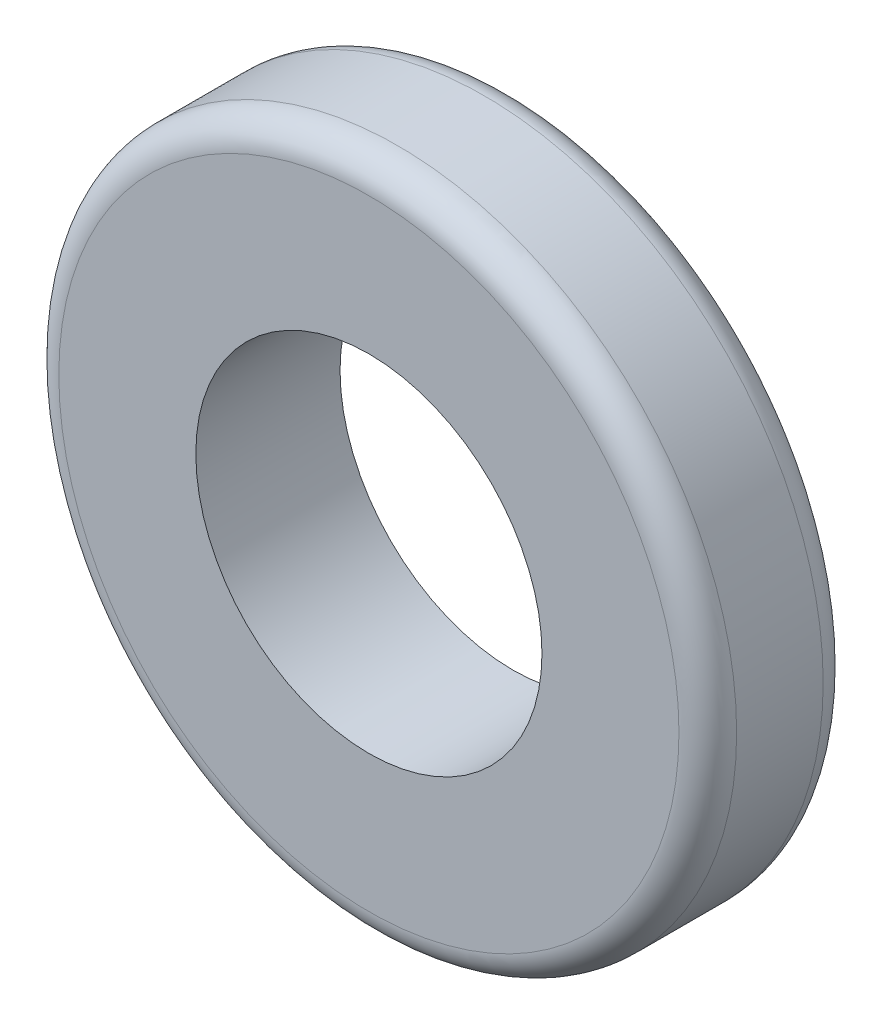
from build123d import *

# Parameters (mm, degrees)
SKETCH1_R           = 23.5
SKETCH1_R_2         = 12
BOSS_EXTRUDE1_DEPTH = 10
FILLET1_R           = 2


with BuildPart() as part:
    # Sketch1 → Boss-Extrude1 (new body)
    with BuildSketch(Plane.XY):
        Circle(SKETCH1_R)
        Circle(SKETCH1_R_2, mode=Mode.SUBTRACT)
    extrude(amount=BOSS_EXTRUDE1_DEPTH)

    # Fillet1
    fillet1_edges = [part.edges().sort_by_distance(p)[0] for p in [
        (-23.5, 0, 0),
        (-23.5, 0, 10),
    ]]
    fillet(fillet1_edges, radius=FILLET1_R)


solid = part.part
